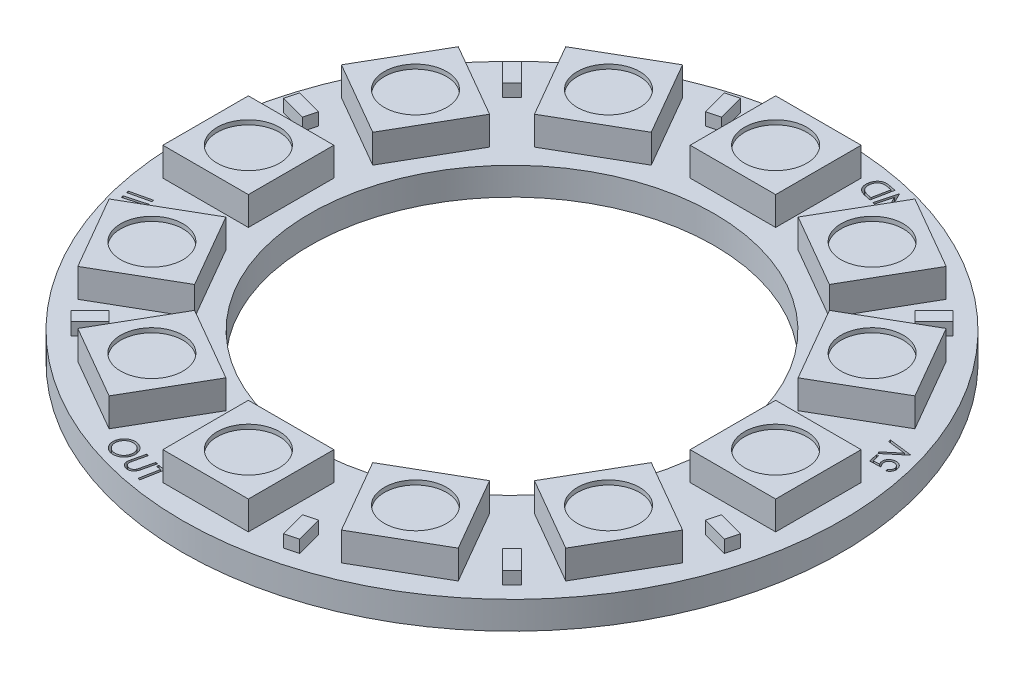
from build123d import *

# Parameters (mm, degrees)
SKETCH1_R           = 18.5
SKETCH1_R_2         = 11.35
BOSS_EXTRUDE1_DEPTH = 1.55
SKETCH2_W           = 4.8
SKETCH2_H           = 4.8
BOSS_EXTRUDE2_DEPTH = 1.6
SKETCH5_R           = 1.75
CUT_EXTRUDE2_DEPTH  = 0.25
CIRPATTERN1_COUNT   = 12
BOSS_EXTRUDE3_DEPTH = 0.7
CIRPATTERN2_COUNT   = 12
CUT_EXTRUDE1_DEPTH  = 0.5


with BuildPart() as part:
    # Sketch1 → Boss-Extrude1 (new body)
    with BuildSketch(Plane(origin=(0, 0, 0), x_dir=(1, 0, 0), z_dir=(0, 1, 0))):
        Circle(SKETCH1_R)
        Circle(SKETCH1_R_2, mode=Mode.SUBTRACT)
    extrude(amount=BOSS_EXTRUDE1_DEPTH)

    # Sketch2 → Boss-Extrude2 (add)
    with BuildSketch(Plane(origin=(0, 1.55, 0), x_dir=(1, 0, 0), z_dir=(0, 1, 0))):
        with Locations((0, 14.8)):
            Rectangle(SKETCH2_W, SKETCH2_H)
    boss_extrude2 = extrude(amount=BOSS_EXTRUDE2_DEPTH)

    # Sketch5 → Cut-Extrude2 (cut)
    with BuildSketch(Plane(origin=(0, 3.15, 0), x_dir=(1, 0, 0), z_dir=(0, 1, 0))):
        with Locations((0, 14.8)):
            Circle(SKETCH5_R)
    cut_extrude2 = extrude(amount=-CUT_EXTRUDE2_DEPTH, mode=Mode.SUBTRACT)

    # CirPattern1: Boss-Extrude2, Cut-Extrude2 ×12 about axis
    cirpattern1_axis = Axis((0, 0, 0), (0, 1, 0))
    for i in range(1, CIRPATTERN1_COUNT):
        add(boss_extrude2.rotate(cirpattern1_axis, i * 360 / CIRPATTERN1_COUNT))
        add(cut_extrude2.rotate(cirpattern1_axis, i * 360 / CIRPATTERN1_COUNT), mode=Mode.SUBTRACT)

    # Sketch3 → Boss-Extrude3 (add)
    with BuildSketch(Plane(origin=(0, 1.55, 0), x_dir=(1, 0, 0), z_dir=(0, 1, 0))):
        Polygon((-4.503326906, 15.357756079), (-4.891555474, 16.806644818), (-4.167111104, 17.000759102), (-3.778882537, 15.551870363), align=None)
    boss_extrude3 = extrude(amount=BOSS_EXTRUDE3_DEPTH)

    # CirPattern2: Boss-Extrude3 ×12 about axis, 4 skipped
    cirpattern2_axis = Axis((0, 1.55, 0), (0, -1, 0))
    add([boss_extrude3.rotate(cirpattern2_axis, i * 360 / CIRPATTERN2_COUNT) for i in range(1, CIRPATTERN2_COUNT) if i not in (1, 3, 7, 9)])

    # Sketch4 → Cut-Extrude1 (cut)
    with BuildSketch(Plane(origin=(0, 1.55, 0), x_dir=(1, 0, 0), z_dir=(0, 1, 0))):
        with BuildLine():
            Line((16.276394454, 4.186654432), (16.386971377, 4.21261597))
            Line((16.386971377, 4.21261597), (16.483846377, 3.799394817))
            Line((16.483846377, 3.799394817), (16.813654069, 3.81574097))
            add(Edge.make_bspline(
                [(16.813654069, 3.81574097), (16.807410574, 3.82720178), (16.795280308, 3.84946858), (16.780205463, 3.883054041), (16.76818705, 3.915425431), (16.762381458, 3.936847997), (16.759567531, 3.947231355)],
                knots=[0, 0, 0, 0, 3.9141e-05, 7.6045e-05, 0.000110343, 0.000142602, 0.000142602, 0.000142602, 0.000142602], degree=3))
            add(Edge.make_bspline(
                [(16.759567531, 3.947231355), (16.75681588, 3.960249633), (16.751415659, 3.985798503), (16.748010069, 4.024235599), (16.747773121, 4.061680824), (16.751849311, 4.098120713), (16.758776197, 4.133698839), (16.770425546, 4.168071052), (16.78534483, 4.201574341), (16.803743256, 4.233956645), (16.82561907, 4.26422987), (16.849886628, 4.292442701), (16.877214811, 4.317416004), (16.907021227, 4.33969035), (16.939344606, 4.359274773), (16.974459331, 4.37577162), (17.012029932, 4.389943411), (17.038417714, 4.39668025), (17.051875223, 4.40011597)],
                knots=[0, 0, 0, 0, 3.9885e-05, 7.8276e-05, 0.000115535, 0.000152037, 0.000188102, 0.000224057, 0.000260644, 0.000298004, 0.000335561, 0.000372534, 0.000409451, 0.000446374, 0.000484013, 0.000522614, 0.000562622, 0.000604261, 0.000604261, 0.000604261, 0.000604261], degree=3))
            add(Edge.make_bspline(
                [(17.051875223, 4.40011597), (17.070716522, 4.403911384), (17.107905508, 4.411402777), (17.164360207, 4.413674402), (17.219971134, 4.409599238), (17.265218443, 4.399572766), (17.300330452, 4.388460358), (17.32567251, 4.378514459), (17.350043343, 4.367339037), (17.373026765, 4.354219703), (17.395120683, 4.340098189), (17.41586702, 4.324084479), (17.43545553, 4.30656549), (17.454109461, 4.287787425), (17.47131696, 4.267518505), (17.487628773, 4.246221911), (17.501819062, 4.223217163), (17.515302289, 4.199388046), (17.526897656, 4.174039746), (17.537682924, 4.147604125), (17.546401931, 4.119703528), (17.551316621, 4.100618407), (17.5537983, 4.090981355)],
                knots=[0, 0, 0, 0, 5.7581e-05, 0.000113653, 0.00016887, 0.00022446, 0.000252208, 0.000279304, 0.000306083, 0.000332561, 0.000358631, 0.00038469, 0.000411081, 0.000437428, 0.000464023, 0.000490802, 0.000517812, 0.000545036, 0.000572889, 0.000601369, 0.000630637, 0.000660492, 0.000660492, 0.000660492, 0.000660492], degree=3))
            add(Edge.make_bspline(
                [(17.5537983, 4.090981355), (17.556259407, 4.079398945), (17.561116724, 4.056539541), (17.56453673, 4.022151404), (17.565345654, 3.988550788), (17.563245884, 3.955702568), (17.557937369, 3.923571745), (17.549472893, 3.892279636), (17.538052071, 3.861698892), (17.523788868, 3.832122585), (17.506629787, 3.804133477), (17.487637826, 3.777666739), (17.46627993, 3.753446244), (17.442601422, 3.731362203), (17.417023586, 3.711086898), (17.388877825, 3.693437911), (17.358939261, 3.677266024), (17.337700217, 3.668517285), (17.326875223, 3.664058278)],
                knots=[0, 0, 0, 0, 3.55e-05, 7.0063e-05, 0.000103485, 0.000136248, 0.000168654, 0.000201017, 0.000233344, 0.000266458, 0.000299356, 0.000331716, 0.000364076, 0.000396048, 0.000428749, 0.000461824, 0.000495591, 0.00053069, 0.00053069, 0.00053069, 0.00053069], degree=3))
            Line((17.326875223, 3.664058278), (17.298990608, 3.783289047))
            add(Edge.make_bspline(
                [(17.298990608, 3.783289047), (17.309123325, 3.788204639), (17.32870273, 3.797703013), (17.355209473, 3.814936646), (17.378291161, 3.833354343), (17.397683485, 3.853670426), (17.413696696, 3.875904961), (17.427138092, 3.900124705), (17.437251684, 3.926768468), (17.445181275, 3.954980661), (17.450359936, 3.984295315), (17.451579332, 4.013975376), (17.450236513, 4.043632592), (17.446210415, 4.06297267), (17.444182915, 4.072712124)],
                knots=[0, 0, 0, 0, 3.3758e-05, 6.523e-05, 9.4625e-05, 0.00012217, 0.000149193, 0.000176627, 0.000205018, 0.000234472, 0.000264467, 0.000294069, 0.000323445, 0.000353245, 0.000353245, 0.000353245, 0.000353245], degree=3))
            add(Edge.make_bspline(
                [(17.444182915, 4.072712124), (17.441766777, 4.082081826), (17.437014309, 4.10051174), (17.426028693, 4.126582622), (17.413444783, 4.151332625), (17.397916103, 4.17431042), (17.379775968, 4.195429008), (17.359378528, 4.215124487), (17.336554091, 4.233146823), (17.311358483, 4.249121488), (17.284644989, 4.26292976), (17.256982114, 4.274421071), (17.228409398, 4.282551417), (17.199184048, 4.287908407), (17.169148392, 4.290195276), (17.138408461, 4.290067902), (17.106855106, 4.28662972), (17.085896962, 4.282190836), (17.075192531, 4.279923663)],
                knots=[0, 0, 0, 0, 2.8991e-05, 5.7024e-05, 8.4656e-05, 0.000112191, 0.000139986, 0.000168037, 0.000197132, 0.000227073, 0.000257392, 0.000287256, 0.000316776, 0.000346339, 0.000376243, 0.000407014, 0.000438444, 0.000471257, 0.000471257, 0.000471257, 0.000471257], degree=3))
            add(Edge.make_bspline(
                [(17.075192531, 4.279923663), (17.065688388, 4.277442797), (17.047078415, 4.272585038), (17.020420227, 4.262633238), (16.995759646, 4.250638624), (16.972857099, 4.236893512), (16.95202085, 4.220950914), (16.933362145, 4.20272765), (16.915990356, 4.183064272), (16.901312321, 4.161089613), (16.888432297, 4.137972359), (16.87863432, 4.113355456), (16.871038405, 4.087965877), (16.866624997, 4.061403676), (16.864283916, 4.033888016), (16.865294003, 4.005332708), (16.868205283, 3.975689306), (16.872504588, 3.955932026), (16.874711761, 3.945789047)],
                knots=[0, 0, 0, 0, 2.9454e-05, 5.7673e-05, 8.5196e-05, 0.000111622, 0.000137681, 0.000163693, 0.000189766, 0.000216236, 0.000242807, 0.00026901, 0.000295558, 0.000322155, 0.000349644, 0.000378259, 0.000407752, 0.000438867, 0.000438867, 0.000438867, 0.000438867], degree=3))
            add(Edge.make_bspline(
                [(16.874711761, 3.945789047), (16.876996912, 3.93709923), (16.881699866, 3.919215157), (16.891291165, 3.892304395), (16.902737714, 3.864255003), (16.917113275, 3.835646633), (16.933186313, 3.805860691), (16.951841993, 3.775431454), (16.972454969, 3.74381761), (16.987601428, 3.72288961), (16.995384838, 3.712135201)],
                knots=[0, 0, 0, 0, 2.6945e-05, 5.5453e-05, 8.5631e-05, 0.000117775, 0.000151444, 0.000187146, 0.000224816, 0.000264636, 0.000264636, 0.000264636, 0.000264636], degree=3))
            Line((16.995384838, 3.712135201), (16.394182915, 3.684250586))
            Line((16.394182915, 3.684250586), (16.276394454, 4.186654432))
        make_face()
        Polygon((16.247481404, 4.273689966), (16.210462173, 4.398689966), (16.986183327, 5.042199582), (15.983058327, 5.166718812), (15.946039096, 5.291718812), (17.243394866, 5.132103428), (17.250846789, 5.107103428), align=None)
        with BuildLine():
            Line((5.086534277, 16.223259573), (5.203120816, 16.275423034))
            add(Edge.make_bspline(
                [(5.203120816, 16.275423034), (5.213729962, 16.255018881), (5.234638572, 16.214806174), (5.272010724, 16.158834033), (5.313420315, 16.107527703), (5.359041889, 16.061717738), (5.407044558, 16.020953215), (5.45732361, 15.986960159), (5.508420296, 15.957970423), (5.544274521, 15.944076525), (5.562015047, 15.93720188)],
                knots=[0, 0, 0, 0, 6.895e-05, 0.000135888, 0.000201512, 0.000266445, 0.000329571, 0.000390112, 0.000448319, 0.000505327, 0.000505327, 0.000505327, 0.000505327], degree=3))
            add(Edge.make_bspline(
                [(5.562015047, 15.93720188), (5.573027797, 15.933525461), (5.595012541, 15.926186229), (5.628702188, 15.917904319), (5.662727465, 15.911576703), (5.697098146, 15.907516415), (5.731780088, 15.905587541), (5.766703782, 15.905833855), (5.801941717, 15.90827556), (5.837267108, 15.912800284), (5.872216551, 15.919441088), (5.906157509, 15.928382774), (5.938971465, 15.939270505), (5.970726287, 15.951858741), (6.00118386, 15.966953252), (6.030455686, 15.983924008), (6.058462901, 16.003107896), (6.085311615, 16.023933838), (6.110688448, 16.046340853), (6.134053855, 16.07034734), (6.155725961, 16.095192585), (6.175245137, 16.121407659), (6.193116391, 16.148426667), (6.208689493, 16.176828926), (6.222890296, 16.20605743), (6.230374155, 16.226473793), (6.234130431, 16.236721111)],
                knots=[0, 0, 0, 0, 3.4818e-05, 6.9508e-05, 0.000103974, 0.000138591, 0.00017326, 0.000208116, 0.000243294, 0.000279163, 0.000314899, 0.000349941, 0.000384376, 0.000418569, 0.000452326, 0.000486258, 0.000519995, 0.000554086, 0.000588143, 0.00062146, 0.000654522, 0.000686974, 0.000719443, 0.000751617, 0.000784089, 0.000816812, 0.000816812, 0.000816812, 0.000816812], degree=3))
            add(Edge.make_bspline(
                [(6.234130431, 16.236721111), (6.237642575, 16.247334636), (6.244654293, 16.2685237), (6.252515231, 16.300987131), (6.258121976, 16.333834158), (6.261157016, 16.366946665), (6.262122046, 16.400424089), (6.260993315, 16.434245222), (6.257245838, 16.468427333), (6.251629541, 16.502758878), (6.24329555, 16.536725247), (6.233467881, 16.5701953), (6.220707098, 16.602417312), (6.206408736, 16.633884543), (6.189385172, 16.664204179), (6.170474663, 16.693685795), (6.149476882, 16.722295283), (6.126121036, 16.749474866), (6.101329611, 16.775647276), (6.074817665, 16.799975765), (6.046811397, 16.82237868), (6.017421582, 16.84307347), (5.986662179, 16.862147244), (5.954294846, 16.879140951), (5.920679358, 16.894715879), (5.897336037, 16.903305861), (5.885572739, 16.907634573)],
                knots=[0, 0, 0, 0, 3.3527e-05, 6.6935e-05, 0.000100091, 0.000133411, 0.000166598, 0.000200514, 0.000234838, 0.000269694, 0.000304794, 0.000339699, 0.000374251, 0.000408669, 0.000443318, 0.000478458, 0.0005137, 0.000549681, 0.000585896, 0.000621794, 0.000657534, 0.000693415, 0.000729573, 0.000766026, 0.00080303, 0.000840619, 0.000840619, 0.000840619, 0.000840619], degree=3))
            add(Edge.make_bspline(
                [(5.885572739, 16.907634573), (5.871215263, 16.912349877), (5.843020002, 16.921609808), (5.800228224, 16.9313945), (5.758127956, 16.937844771), (5.716529896, 16.94010336), (5.675582687, 16.939336561), (5.635161442, 16.934484255), (5.595481121, 16.925686823), (5.556586743, 16.913779868), (5.519266799, 16.89845561), (5.484006592, 16.880145026), (5.45117071, 16.858988209), (5.420867969, 16.834682631), (5.39300261, 16.807557889), (5.36759145, 16.777386792), (5.344388032, 16.744583341), (5.331343184, 16.720831411), (5.324755431, 16.708836496)],
                knots=[0, 0, 0, 0, 4.5315e-05, 8.899e-05, 0.000131519, 0.000172935, 0.000213811, 0.000254242, 0.000294839, 0.000335594, 0.000376127, 0.000415693, 0.000454633, 0.000493113, 0.000532041, 0.0005711, 0.000611313, 0.00065234, 0.00065234, 0.00065234, 0.00065234], degree=3))
            Line((5.324755431, 16.708836496), (5.684130431, 16.582153803))
            Line((5.684130431, 16.582153803), (5.645668893, 16.473499957))
            Line((5.645668893, 16.473499957), (5.159851585, 16.644653803))
            add(Edge.make_bspline(
                [(5.159851585, 16.644653803), (5.167938434, 16.665704052), (5.183725608, 16.706798421), (5.212361204, 16.764784821), (5.245045354, 16.817403902), (5.280832648, 16.865348654), (5.320467097, 16.908136133), (5.36363087, 16.945933507), (5.410706084, 16.978266172), (5.460786397, 17.005640793), (5.513503575, 17.027492754), (5.568069157, 17.043860015), (5.624407621, 17.053569957), (5.682140874, 17.057625839), (5.741360948, 17.056031824), (5.801967132, 17.047688074), (5.864302821, 17.034169452), (5.905552137, 17.020596005), (5.926678508, 17.013644188)],
                knots=[0, 0, 0, 0, 6.7627e-05, 0.000132022, 0.00019366, 0.000253228, 0.000311232, 0.000368309, 0.000424987, 0.000482215, 0.000539223, 0.000595887, 0.000652757, 0.000710354, 0.000769272, 0.000830128, 0.000893643, 0.000960325, 0.000960325, 0.000960325, 0.000960325], degree=3))
            add(Edge.make_bspline(
                [(5.926678508, 17.013644188), (5.939456135, 17.008934645), (5.964732493, 16.999618353), (6.001500637, 16.984122342), (6.036467697, 16.966779494), (6.070141593, 16.948802692), (6.101895135, 16.928844291), (6.132318839, 16.908070063), (6.160887438, 16.885551158), (6.188097696, 16.862150462), (6.213474041, 16.837186633), (6.237222127, 16.810953521), (6.259716522, 16.783568687), (6.280316007, 16.754670267), (6.299450151, 16.724554979), (6.316622154, 16.692965374), (6.332668941, 16.660335698), (6.341799551, 16.637743169), (6.346390047, 16.626384573)],
                knots=[0, 0, 0, 0, 4.0852e-05, 8.0812e-05, 0.000119622, 0.000157915, 0.00019527, 0.000232077, 0.000268382, 0.000304338, 0.000339695, 0.000375091, 0.000410457, 0.000445946, 0.000481492, 0.000517426, 0.000553764, 0.000590506, 0.000590506, 0.000590506, 0.000590506], degree=3))
            add(Edge.make_bspline(
                [(6.346390047, 16.626384573), (6.352714348, 16.60869429), (6.365211403, 16.57373763), (6.378317403, 16.520028949), (6.386893028, 16.466329232), (6.390250821, 16.412482309), (6.388598648, 16.358631676), (6.381655161, 16.304773771), (6.370308431, 16.250735003), (6.358891177, 16.215397993), (6.353120816, 16.197538419)],
                knots=[0, 0, 0, 0, 5.6329e-05, 0.000111307, 0.000165569, 0.000219281, 0.000272913, 0.000326939, 0.000382008, 0.000438281, 0.000438281, 0.000438281, 0.000438281], degree=3))
            add(Edge.make_bspline(
                [(6.353120816, 16.197538419), (6.348250291, 16.184405807), (6.338554104, 16.158261553), (6.320928596, 16.120506945), (6.300869183, 16.084508949), (6.279018219, 16.049767477), (6.254323008, 16.017030746), (6.22795449, 15.985320336), (6.198993591, 15.955469374), (6.167794066, 15.927508027), (6.135089726, 15.901439331), (6.101072234, 15.877644777), (6.065658139, 15.856864518), (6.029201626, 15.838168006), (5.991462131, 15.822068794), (5.952425393, 15.808566111), (5.912149902, 15.797801605), (5.87089751, 15.789405011), (5.828921885, 15.783511471), (5.786490255, 15.78101124), (5.743790762, 15.781030171), (5.700799093, 15.783507769), (5.65756619, 15.789521523), (5.613969558, 15.797909879), (5.570002937, 15.809078796), (5.541044218, 15.818824725), (5.526438124, 15.823740342)],
                knots=[0, 0, 0, 0, 4.2008e-05, 8.3628e-05, 0.000124838, 0.000165583, 0.000206641, 0.000247761, 0.000289241, 0.000331283, 0.000373368, 0.000414645, 0.000455706, 0.000496451, 0.000537484, 0.000578688, 0.000620264, 0.000662457, 0.000704918, 0.000747309, 0.000789857, 0.000832967, 0.000876381, 0.000920696, 0.000966114, 0.001012334, 0.001012334, 0.001012334, 0.001012334], degree=3))
            add(Edge.make_bspline(
                [(5.526438124, 15.823740342), (5.514602589, 15.828004936), (5.491082871, 15.83647959), (5.457062888, 15.851610931), (5.423878277, 15.86761715), (5.392022684, 15.885546317), (5.360946384, 15.904439987), (5.331010657, 15.924875062), (5.302509556, 15.947141427), (5.274671137, 15.970447464), (5.247917937, 15.995533646), (5.222147299, 16.022489849), (5.197488635, 16.051464377), (5.173234719, 16.081978313), (5.15035511, 16.114762393), (5.127966991, 16.149093151), (5.106383449, 16.185254794), (5.093223361, 16.210452128), (5.086534277, 16.223259573)],
                knots=[0, 0, 0, 0, 3.7729e-05, 7.4975e-05, 0.000111635, 0.000148222, 0.000184585, 0.000220723, 0.000256881, 0.000293046, 0.00032961, 0.000366845, 0.00040486, 0.000443717, 0.000483734, 0.000524739, 0.000566666, 0.000610006, 0.000610006, 0.000610006, 0.000610006], degree=3))
        make_face()
        Polygon((5.134632488, 17.247619302), (4.824536334, 16.098340456), (4.799536334, 16.105071225), (4.272853642, 17.191128918), (4.035353642, 16.311321225), (3.922132488, 16.341850072), (4.232228642, 17.491128918), (4.257949795, 17.484157764), (4.781507488, 16.410840456), (5.015882488, 17.279590456), align=None)
        with BuildLine():
            Line((3.942067674, 17.558553237), (3.71009652, 16.387159006))
            Line((3.71009652, 16.387159006), (3.467308059, 16.435235929))
            add(Edge.make_bspline(
                [(3.467308059, 16.435235929), (3.446212692, 16.439542001), (3.405444604, 16.447863749), (3.346840749, 16.461533934), (3.293057352, 16.475660927), (3.24397607, 16.490106473), (3.1996265, 16.504793722), (3.160064295, 16.520174791), (3.125244899, 16.535889577), (3.104181297, 16.54752702), (3.094231135, 16.553024391)],
                knots=[0, 0, 0, 0, 6.4589e-05, 0.000124822, 0.000180504, 0.000231389, 0.000278292, 0.00032061, 0.000358688, 0.00039278, 0.00039278, 0.00039278, 0.00039278], degree=3))
            add(Edge.make_bspline(
                [(3.094231135, 16.553024391), (3.081356316, 16.560996997), (3.055927264, 16.576743692), (3.020480134, 16.603627686), (2.987850261, 16.632751546), (2.958284253, 16.664437942), (2.931194874, 16.69802539), (2.907349419, 16.734188017), (2.886109519, 16.772361131), (2.868158079, 16.812793557), (2.853289577, 16.854925663), (2.841394338, 16.898354951), (2.833384436, 16.943101207), (2.828142156, 16.988867424), (2.826933237, 17.035885981), (2.828566692, 17.083981413), (2.833586162, 17.133308621), (2.839523992, 17.166278937), (2.842548443, 17.183072468)],
                knots=[0, 0, 0, 0, 4.541e-05, 8.9689e-05, 0.000133268, 0.000176464, 0.000219562, 0.000262564, 0.000306249, 0.000350475, 0.000395105, 0.00044018, 0.000485396, 0.000531348, 0.000578245, 0.000626351, 0.000675649, 0.000726826, 0.000726826, 0.000726826, 0.000726826], degree=3))
            add(Edge.make_bspline(
                [(2.842548443, 17.183072468), (2.845681902, 17.197452001), (2.851867051, 17.22583583), (2.863646321, 17.267208235), (2.877620798, 17.30678679), (2.893749414, 17.344608857), (2.911968149, 17.380718825), (2.932469551, 17.414875521), (2.95490627, 17.447276584), (2.979342327, 17.477709494), (3.005500793, 17.505923325), (3.032675157, 17.531982795), (3.06086246, 17.55559236), (3.0899302, 17.576855346), (3.120127045, 17.595399353), (3.151212657, 17.611554324), (3.183226095, 17.625349477), (3.216592797, 17.636510743), (3.25176802, 17.645279717), (3.289411067, 17.651211786), (3.329663528, 17.654404955), (3.372532702, 17.655474423), (3.418105229, 17.653285508), (3.466296297, 17.648919421), (3.517198718, 17.64232263), (3.551713328, 17.635738784), (3.56947152, 17.632351314)],
                knots=[0, 0, 0, 0, 4.4143e-05, 8.7134e-05, 0.00012895, 0.000169984, 0.000210405, 0.000250188, 0.000289397, 0.000328553, 0.000367169, 0.000404743, 0.000441431, 0.000477396, 0.000512688, 0.000547631, 0.000582414, 0.000617154, 0.000653068, 0.000691046, 0.000731331, 0.000774131, 0.000819604, 0.000868115, 0.00091928, 0.000973505, 0.000973505, 0.000973505, 0.000973505], degree=3))
            Line((3.56947152, 17.632351314), (3.942067674, 17.558553237))
        make_face()
        with BuildLine():
            Line((3.807933059, 17.470332083), (3.67259652, 17.497014775))
            add(Edge.make_bspline(
                [(3.67259652, 17.497014775), (3.65313493, 17.500749645), (3.615703786, 17.507933049), (3.561738643, 17.517478877), (3.512163254, 17.524564275), (3.467149791, 17.530313985), (3.426488117, 17.533859533), (3.390256769, 17.536031146), (3.358448641, 17.535935745), (3.338856477, 17.534305943), (3.329808059, 17.533553237)],
                knots=[0, 0, 0, 0, 5.9451e-05, 0.000114344, 0.000164385, 0.000209676, 0.000250461, 0.00028681, 0.000318542, 0.000345773, 0.000345773, 0.000345773, 0.000345773], degree=3))
            add(Edge.make_bspline(
                [(3.329808059, 17.533553237), (3.318318104, 17.531886916), (3.295571984, 17.528588179), (3.26226602, 17.520586532), (3.230284758, 17.510000948), (3.199642661, 17.496991834), (3.170337548, 17.481524139), (3.142462631, 17.463456552), (3.11585108, 17.442872853), (3.090717565, 17.419923696), (3.067405036, 17.394601211), (3.045904586, 17.367309756), (3.026367225, 17.338052824), (3.00937882, 17.306430458), (2.993834814, 17.273169171), (2.981041098, 17.237598607), (2.969800948, 17.200230079), (2.964170503, 17.17438229), (2.961298443, 17.161197468)],
                knots=[0, 0, 0, 0, 3.4817e-05, 6.8925e-05, 0.0001026, 0.000135774, 0.000168679, 0.000201884, 0.000235301, 0.000269501, 0.000303863, 0.00033844, 0.000373642, 0.000409249, 0.000446035, 0.00048368, 0.000522546, 0.000563013, 0.000563013, 0.000563013, 0.000563013], degree=3))
            add(Edge.make_bspline(
                [(2.961298443, 17.161197468), (2.958781149, 17.147283829), (2.953825794, 17.119894486), (2.949827122, 17.0789132), (2.948539001, 17.038993911), (2.950238811, 17.000024546), (2.954689411, 16.962144479), (2.962351281, 16.925314827), (2.97222795, 16.88941905), (2.985601342, 16.854850704), (3.001323423, 16.821753548), (3.019755611, 16.790467398), (3.040641438, 16.761235961), (3.063864943, 16.733802632), (3.08970474, 16.708462437), (3.118166835, 16.685280041), (3.148785276, 16.663553107), (3.170794537, 16.651149997), (3.18197152, 16.644851314)],
                knots=[0, 0, 0, 0, 4.2404e-05, 8.3473e-05, 0.000123395, 0.000162134, 0.000200388, 0.000237679, 0.000274892, 0.000311946, 0.000348718, 0.000384709, 0.000420729, 0.000456371, 0.000492408, 0.000529127, 0.000566406, 0.000604872, 0.000604872, 0.000604872, 0.000604872], degree=3))
            add(Edge.make_bspline(
                [(3.18197152, 16.644851314), (3.191288267, 16.640157082), (3.211133879, 16.630157895), (3.244111806, 16.616941031), (3.28153698, 16.603496248), (3.323733224, 16.590312085), (3.370613358, 16.57749174), (3.422042199, 16.564485363), (3.478146635, 16.551733449), (3.51720943, 16.543881753), (3.537500366, 16.539803237)],
                knots=[0, 0, 0, 0, 3.1285e-05, 6.664e-05, 0.000106483, 0.000150579, 0.000199219, 0.000252273, 0.000309714, 0.000371802, 0.000371802, 0.000371802, 0.000371802], degree=3))
            Line((3.537500366, 16.539803237), (3.620433059, 16.523457083))
            Line((3.620433059, 16.523457083), (3.807933059, 17.470332083))
        make_face(mode=Mode.SUBTRACT)
        Polygon((-16.387705354, -3.736551203), (-16.361022662, -3.852656973), (-17.5213592, -4.120445434), (-17.548041893, -4.004339665), align=None)
        Polygon((-17.454628259, -4.379325086), (-16.305349412, -4.058411624), (-16.298378259, -4.083411624), (-16.964724412, -5.093267393), (-16.08491672, -4.847594316), (-16.053426335, -4.96081547), (-17.202705182, -5.281728932), (-17.20991672, -5.256007778), (-16.552705182, -4.255527009), (-17.421455182, -4.498075086), align=None)
        with BuildLine():
            add(Edge.make_bspline(
                [(-4.987296888, -16.004644771), (-4.966303958, -16.01168502), (-4.925006111, -16.025534785), (-4.86678096, -16.053033682), (-4.812729195, -16.084636723), (-4.76287235, -16.120772256), (-4.717614508, -16.161885685), (-4.676365306, -16.207323294), (-4.639858117, -16.257581136), (-4.607868595, -16.311599158), (-4.580980272, -16.368201867), (-4.560296889, -16.426386947), (-4.545327134, -16.485262172), (-4.537283015, -16.545095121), (-4.53501654, -16.605658037), (-4.539278747, -16.667007027), (-4.549487972, -16.729220462), (-4.561163465, -16.770127275), (-4.56710458, -16.790942848)],
                knots=[0, 0, 0, 0, 6.6378e-05, 0.00013058, 0.000192751, 0.000254007, 0.000314936, 0.000375865, 0.000437793, 0.000500952, 0.000563964, 0.000625475, 0.000685934, 0.000745869, 0.000806244, 0.000867438, 0.000930076, 0.000994972, 0.000994972, 0.000994972, 0.000994972], degree=3))
            add(Edge.make_bspline(
                [(-4.56710458, -16.790942848), (-4.574003531, -16.811288022), (-4.587560368, -16.851267465), (-4.614395458, -16.907896181), (-4.645665981, -16.960486706), (-4.681636876, -17.009158247), (-4.722505512, -17.053528519), (-4.767956555, -17.093942057), (-4.818221195, -17.130044306), (-4.872447411, -17.16168462), (-4.929214203, -17.188626037), (-4.987580935, -17.209246298), (-5.046517137, -17.224259439), (-5.106275943, -17.232312919), (-5.166663084, -17.23447957), (-5.227723017, -17.230666665), (-5.28948442, -17.22025659), (-5.330097716, -17.208793538), (-5.350758427, -17.202962079)],
                knots=[0, 0, 0, 0, 6.4406e-05, 0.000126561, 0.000187575, 0.00024772, 0.000307776, 0.000368224, 0.000429869, 0.000493113, 0.000556343, 0.00061808, 0.000678539, 0.000738474, 0.000798609, 0.000859548, 0.000921711, 0.000986081, 0.000986081, 0.000986081, 0.000986081], degree=3))
            add(Edge.make_bspline(
                [(-5.350758427, -17.202962079), (-5.371262118, -17.1959769), (-5.411628757, -17.182224829), (-5.468788642, -17.155209836), (-5.522050329, -17.12395455), (-5.571029669, -17.087762472), (-5.615745626, -17.046853082), (-5.656402142, -17.001398374), (-5.692717833, -16.951123695), (-5.724696285, -16.896976916), (-5.751364859, -16.840187825), (-5.772571761, -16.782247732), (-5.787323399, -16.723593882), (-5.795721329, -16.664375603), (-5.798246351, -16.604601024), (-5.794158848, -16.544313365), (-5.784534004, -16.483274025), (-5.773135714, -16.443248458), (-5.767344965, -16.422914002)],
                knots=[0, 0, 0, 0, 6.4939e-05, 0.00012785, 0.000189277, 0.000249952, 0.000310185, 0.000370793, 0.000432579, 0.000495944, 0.000559174, 0.00062054, 0.000680766, 0.000740258, 0.000799682, 0.000859901, 0.000921274, 0.000984653, 0.000984653, 0.000984653, 0.000984653], degree=3))
            add(Edge.make_bspline(
                [(-5.767344965, -16.422914002), (-5.762870322, -16.409389708), (-5.754005265, -16.382595694), (-5.737748078, -16.343734001), (-5.71926099, -16.306486842), (-5.698496605, -16.270780908), (-5.675594783, -16.236597218), (-5.650641522, -16.203765073), (-5.623054527, -16.172786166), (-5.593621959, -16.14320595), (-5.56224347, -16.115842955), (-5.529798743, -16.090315014), (-5.495792422, -16.067871904), (-5.460815103, -16.047439587), (-5.42450766, -16.029792088), (-5.387112771, -16.014176252), (-5.348387589, -16.001585529), (-5.308727535, -15.991266657), (-5.268537736, -15.98325347), (-5.228119326, -15.978285508), (-5.187733438, -15.975822069), (-5.147424814, -15.976101355), (-5.107166413, -15.978880976), (-5.067053312, -15.984850061), (-5.026935092, -15.993073496), (-5.000551363, -16.000775495), (-4.987296888, -16.004644771)],
                knots=[0, 0, 0, 0, 4.2724e-05, 8.4643e-05, 0.000126247, 0.000167394, 0.000208463, 0.000249619, 0.000291002, 0.000332817, 0.000374719, 0.000415832, 0.000456567, 0.00049685, 0.000537272, 0.000577583, 0.000618328, 0.000659316, 0.000700472, 0.000741171, 0.000781387, 0.000821773, 0.000862021, 0.000902339, 0.000943356, 0.000984763, 0.000984763, 0.000984763, 0.000984763], degree=3))
        make_face()
        with BuildLine():
            add(Edge.make_bspline(
                [(-5.016864196, -16.117865925), (-5.027410207, -16.114864706), (-5.048357011, -16.108903594), (-5.080273019, -16.102043381), (-5.112433201, -16.097826448), (-5.144871457, -16.095615199), (-5.177477608, -16.095630967), (-5.210397525, -16.097827473), (-5.243474791, -16.102160199), (-5.27657756, -16.108580587), (-5.309099591, -16.117339551), (-5.340939289, -16.127483325), (-5.371549492, -16.140135992), (-5.401056049, -16.154568036), (-5.429649753, -16.170606304), (-5.456735013, -16.18908751), (-5.483150074, -16.209021556), (-5.508164457, -16.231005919), (-5.531770109, -16.254683991), (-5.553939868, -16.279590888), (-5.574196184, -16.306102886), (-5.592440701, -16.33419246), (-5.609340021, -16.363503102), (-5.624441949, -16.394251103), (-5.637834949, -16.426432018), (-5.645134572, -16.448662685), (-5.64883535, -16.459933233)],
                knots=[0, 0, 0, 0, 3.289e-05, 6.5326e-05, 9.7827e-05, 0.000130111, 0.000162804, 0.000195568, 0.000229022, 0.000262824, 0.000296642, 0.000330014, 0.000363003, 0.0003959, 0.000428519, 0.000461255, 0.000494188, 0.000527747, 0.000561062, 0.00059444, 0.000627711, 0.000661047, 0.000694859, 0.000729153, 0.00076375, 0.000799327, 0.000799327, 0.000799327, 0.000799327], degree=3))
            add(Edge.make_bspline(
                [(-5.64883535, -16.459933233), (-5.653560276, -16.476604878), (-5.662875066, -16.509471612), (-5.671188515, -16.559488118), (-5.674793833, -16.608933818), (-5.672601443, -16.657723275), (-5.666328685, -16.705952434), (-5.654318069, -16.753525013), (-5.637397074, -16.80050113), (-5.615834921, -16.846325347), (-5.590434155, -16.890066049), (-5.561193667, -16.930263339), (-5.52914514, -16.966964985), (-5.493523559, -16.999481879), (-5.454956052, -17.028510515), (-5.413058622, -17.053605801), (-5.368046184, -17.074918497), (-5.336293785, -17.085719021), (-5.32022958, -17.091183233)],
                knots=[0, 0, 0, 0, 5.1951e-05, 0.000102417, 0.00015181, 0.000200406, 0.000248681, 0.00029748, 0.000347283, 0.000398256, 0.000449214, 0.000498788, 0.000547159, 0.000595136, 0.000643213, 0.000691736, 0.000741416, 0.000792287, 0.000792287, 0.000792287, 0.000792287], degree=3))
            add(Edge.make_bspline(
                [(-5.32022958, -17.091183233), (-5.309207954, -17.094367736), (-5.287403449, -17.100667759), (-5.254229812, -17.107623294), (-5.221071347, -17.112452219), (-5.187909775, -17.115069413), (-5.15473569, -17.115672494), (-5.121593467, -17.113549583), (-5.088317339, -17.109867589), (-5.055240591, -17.103563332), (-5.022776441, -17.095128567), (-4.991052108, -17.085117517), (-4.960567111, -17.07280255), (-4.931154965, -17.058621401), (-4.902921147, -17.042410867), (-4.875708975, -17.02433458), (-4.849475957, -17.004405013), (-4.824540074, -16.982519581), (-4.800888938, -16.959014271), (-4.779251349, -16.933724643), (-4.758694142, -16.907522996), (-4.740674523, -16.879438664), (-4.723552034, -16.850377908), (-4.708870995, -16.819645749), (-4.695686073, -16.787623966), (-4.68836782, -16.765590055), (-4.684652657, -16.754404387)],
                knots=[0, 0, 0, 0, 3.4408e-05, 6.807e-05, 0.00010159, 0.000134868, 0.000167804, 0.000201033, 0.000234428, 0.000268185, 0.000301943, 0.000335012, 0.00036791, 0.000400487, 0.000432897, 0.000465499, 0.000498432, 0.000531652, 0.000564967, 0.000598368, 0.000631447, 0.000664784, 0.000698387, 0.000732576, 0.000766859, 0.000802209, 0.000802209, 0.000802209, 0.000802209], degree=3))
            add(Edge.make_bspline(
                [(-4.684652657, -16.754404387), (-4.681383026, -16.743224118), (-4.674892188, -16.721029168), (-4.667781817, -16.687357065), (-4.662697959, -16.653890443), (-4.65971486, -16.620652456), (-4.659301745, -16.587635697), (-4.660985536, -16.554877269), (-4.664767968, -16.522242091), (-4.671159501, -16.489937291), (-4.679156666, -16.457988433), (-4.689607425, -16.426959076), (-4.70186575, -16.39671903), (-4.716331758, -16.367447825), (-4.732734214, -16.338904623), (-4.751277749, -16.31133349), (-4.771718568, -16.284500352), (-4.794345297, -16.259015397), (-4.818063732, -16.234573355), (-4.843315946, -16.212149364), (-4.869384737, -16.191336561), (-4.896994188, -16.172959554), (-4.925240199, -16.155951612), (-4.954849367, -16.141372285), (-4.985228654, -16.128177141), (-5.006306059, -16.12130722), (-5.016864196, -16.117865925)],
                knots=[0, 0, 0, 0, 3.4935e-05, 6.9353e-05, 0.000103146, 0.000136444, 0.00016938, 0.000202116, 0.000234795, 0.000267843, 0.000300842, 0.000333529, 0.000365982, 0.000398664, 0.000431402, 0.000464671, 0.000498278, 0.000532515, 0.000566852, 0.00060039, 0.000633766, 0.000666835, 0.000699816, 0.000732604, 0.000765778, 0.000799075, 0.000799075, 0.000799075, 0.000799075], degree=3))
        make_face(mode=Mode.SUBTRACT)
        with BuildLine():
            Line((-4.229881341, -16.263554662), (-4.114015956, -16.290718124))
            Line((-4.114015956, -16.290718124), (-4.278198649, -16.991198893))
            add(Edge.make_bspline(
                [(-4.278198649, -16.991198893), (-4.28055784, -17.00104657), (-4.285059365, -17.019836723), (-4.290903753, -17.046655274), (-4.296348344, -17.070482867), (-4.300607846, -17.091507967), (-4.304300227, -17.10958829), (-4.306866504, -17.124840348), (-4.30898709, -17.137068516), (-4.309645308, -17.144319233), (-4.309929418, -17.147448893)],
                knots=[0, 0, 0, 0, 3.0378e-05, 5.7964e-05, 8.2342e-05, 0.000103699, 0.00012232, 0.000137694, 0.000150103, 0.000159527, 0.000159527, 0.000159527, 0.000159527], degree=3))
            add(Edge.make_bspline(
                [(-4.309929418, -17.147448893), (-4.310807928, -17.158899012), (-4.312509195, -17.181072597), (-4.311095096, -17.213514088), (-4.306103229, -17.243812853), (-4.297444967, -17.272237258), (-4.284297225, -17.299007052), (-4.266809071, -17.324718861), (-4.244285712, -17.349213786), (-4.21812356, -17.37261318), (-4.188869311, -17.393447004), (-4.158179893, -17.411075701), (-4.12631796, -17.424872918), (-4.104323705, -17.430952213), (-4.093342879, -17.433987354)],
                knots=[0, 0, 0, 0, 3.4429e-05, 6.6673e-05, 9.7142e-05, 0.000126338, 0.000155473, 0.000186277, 0.000219296, 0.000255049, 0.000291405, 0.000326826, 0.000361073, 0.000395219, 0.000395219, 0.000395219, 0.000395219], degree=3))
            add(Edge.make_bspline(
                [(-4.093342879, -17.433987354), (-4.083758998, -17.435888167), (-4.064713745, -17.439665495), (-4.035581367, -17.441455631), (-4.006341542, -17.440252855), (-3.977158533, -17.435957707), (-3.948696082, -17.428567862), (-3.92158392, -17.418199209), (-3.896165637, -17.404893805), (-3.872457116, -17.38866567), (-3.850456481, -17.369529776), (-3.830295944, -17.347560396), (-3.811762843, -17.322919921), (-3.801478999, -17.304786004), (-3.796227495, -17.295525816)],
                knots=[0, 0, 0, 0, 2.9285e-05, 5.8195e-05, 8.7306e-05, 0.00011695, 0.000146511, 0.00017535, 0.000203844, 0.000232381, 0.000261349, 0.000291118, 0.000321696, 0.000353604, 0.000353604, 0.000353604, 0.000353604], degree=3))
            add(Edge.make_bspline(
                [(-3.796227495, -17.295525816), (-3.794244956, -17.291626707), (-3.789833362, -17.282950313), (-3.78402572, -17.268004388), (-3.777811644, -17.250091468), (-3.771003367, -17.229318354), (-3.76455532, -17.205364823), (-3.756808297, -17.17874575), (-3.749582817, -17.148831672), (-3.744543222, -17.12789747), (-3.741900572, -17.116920047)],
                knots=[0, 0, 0, 0, 1.3116e-05, 2.9186e-05, 4.804e-05, 7.001e-05, 9.4742e-05, 0.000122445, 0.00015317, 0.000187045, 0.000187045, 0.000187045, 0.000187045], degree=3))
            Line((-3.741900572, -17.116920047), (-3.577717879, -16.416439277))
            Line((-3.577717879, -16.416439277), (-3.46161211, -16.443602739))
            Line((-3.46161211, -16.443602739), (-3.625794802, -17.144083508))
            add(Edge.make_bspline(
                [(-3.625794802, -17.144083508), (-3.628863142, -17.156677561), (-3.634862625, -17.181302539), (-3.644596922, -17.217118445), (-3.655312441, -17.250694337), (-3.665973504, -17.282396332), (-3.677617879, -17.311802377), (-3.689212848, -17.339387782), (-3.701863434, -17.36463569), (-3.714774971, -17.388258366), (-3.729063402, -17.410052864), (-3.744870626, -17.430486802), (-3.762328202, -17.449696167), (-3.781798174, -17.4674986), (-3.80261585, -17.484397133), (-3.825411463, -17.49984522), (-3.84992008, -17.513885355), (-3.875722774, -17.52692604), (-3.902837646, -17.538033726), (-3.930939226, -17.5465989), (-3.959616864, -17.552977591), (-3.988998669, -17.556503573), (-4.019070326, -17.557780409), (-4.049849377, -17.556194547), (-4.08128258, -17.552423866), (-4.102184942, -17.548010465), (-4.112814033, -17.5457662)],
                knots=[0, 0, 0, 0, 3.8887e-05, 7.6036e-05, 0.000111313, 0.000144609, 0.000176348, 0.000206176, 0.000234342, 0.000261029, 0.000286898, 0.00031243, 0.000338464, 0.00036466, 0.000391503, 0.000418839, 0.000447165, 0.000476191, 0.000505518, 0.000534945, 0.000564225, 0.000593534, 0.000623607, 0.00065441, 0.000685895, 0.000718472, 0.000718472, 0.000718472, 0.000718472], degree=3))
            add(Edge.make_bspline(
                [(-4.112814033, -17.5457662), (-4.124231754, -17.542861235), (-4.146702589, -17.537144068), (-4.179255149, -17.526284888), (-4.21011964, -17.513551541), (-4.239199529, -17.498905941), (-4.266483842, -17.482463826), (-4.292136296, -17.464427676), (-4.315917747, -17.444383146), (-4.338037715, -17.422859416), (-4.357934409, -17.39982109), (-4.375500898, -17.37575588), (-4.390784521, -17.350879245), (-4.403606209, -17.325060976), (-4.413849677, -17.298284355), (-4.422211237, -17.2707931), (-4.427746275, -17.2423447), (-4.429486626, -17.223030358), (-4.43036211, -17.213314277)],
                knots=[0, 0, 0, 0, 3.5336e-05, 6.9543e-05, 0.000102846, 0.000135419, 0.000167122, 0.000198336, 0.000229391, 0.000260329, 0.000290835, 0.000320597, 0.000349621, 0.000378324, 0.000406939, 0.000435536, 0.000464435, 0.000493689, 0.000493689, 0.000493689, 0.000493689], degree=3))
            add(Edge.make_bspline(
                [(-4.43036211, -17.213314277), (-4.430591427, -17.206744619), (-4.431089264, -17.192482185), (-4.430316442, -17.169433347), (-4.427736639, -17.143144701), (-4.423858443, -17.113566664), (-4.418537106, -17.080706056), (-4.411763433, -17.044646943), (-4.403556415, -17.005383253), (-4.397317539, -16.978207363), (-4.394064033, -16.964035431)],
                knots=[0, 0, 0, 0, 1.9717e-05, 4.2806e-05, 6.9118e-05, 9.8934e-05, 0.000132289, 0.000168969, 0.000208995, 0.000252616, 0.000252616, 0.000252616, 0.000252616], degree=3))
            Line((-4.394064033, -16.964035431), (-4.229881341, -16.263554662))
        make_face()
        Polygon((-3.364721801, -16.586705736), (-3.34380834, -16.472763429), (-2.701019878, -16.590792275), (-2.72193334, -16.704734582), (-2.983231417, -16.656657659), (-3.177462186, -17.714109582), (-3.29693334, -17.692234582), (-3.10270257, -16.634782659), align=None)
    extrude(amount=-CUT_EXTRUDE1_DEPTH, mode=Mode.SUBTRACT)


solid = part.part
